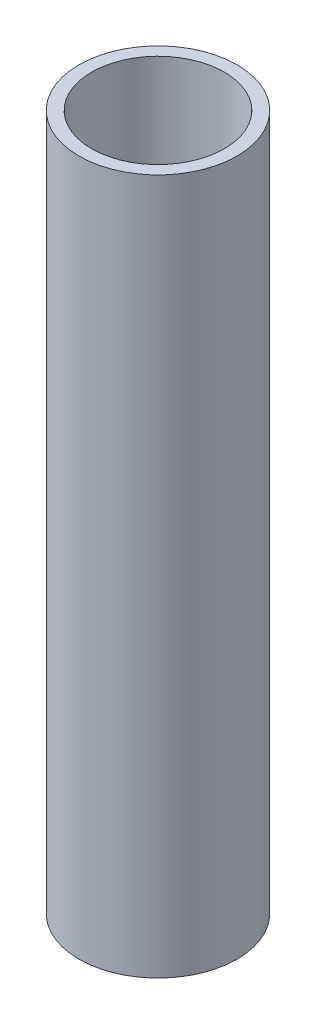
from build123d import *


with BuildPart() as part:
    # Esboço3 → Revolução1 (revolve)
    with BuildSketch(Plane.XY):
        Polygon((10.5, 110), (12.5, 110), (12.5, 0), (3, 0), (3, 3), (8.5, 3), (8.5, 86), (10.5, 86), align=None)
    revolve(axis=Axis((0, 26.021282523, 0), (0, -1, 0)))


solid = part.part
